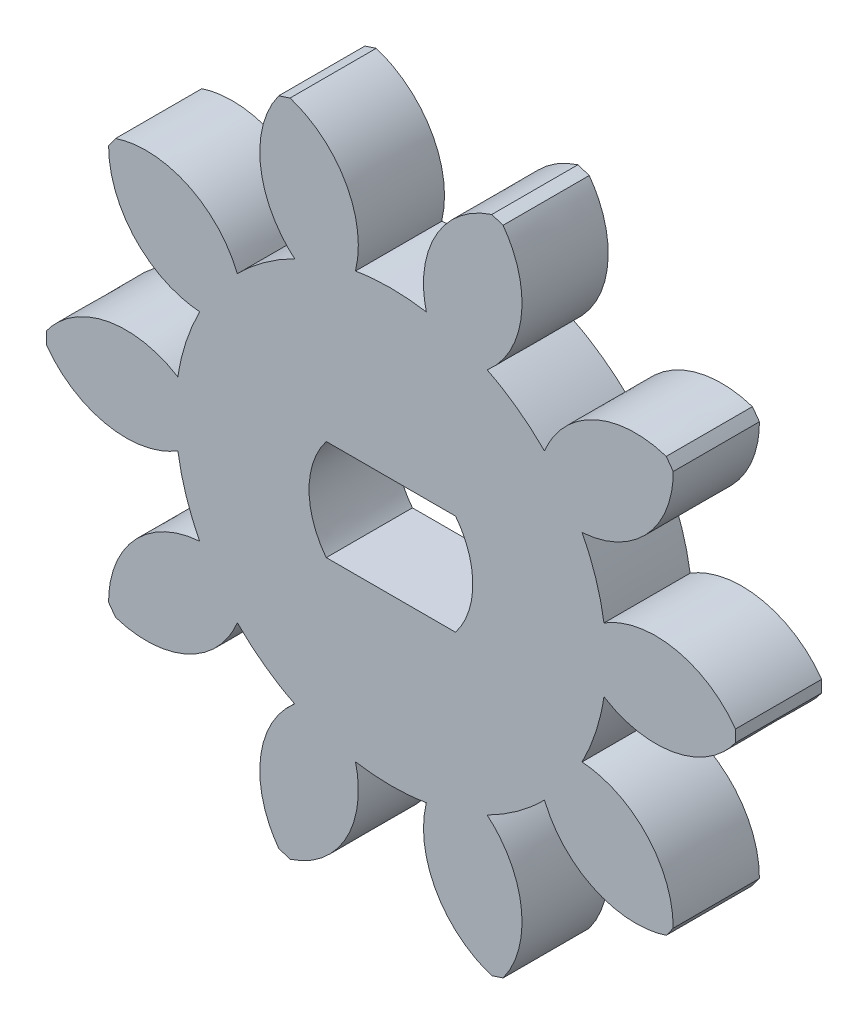
from build123d import *

# Parameters (mm, degrees)
SALIENTE_EXTRUIR1_DEPTH = 3


with BuildPart() as part:
    # Croquis1 → Saliente-Extruir1 (new body)
    with BuildSketch(Plane.XY):
        with BuildLine():
            add(Edge.make_bspline(
                [(389.936156465, -257.964269658), (389.256388965, -256.299793547), (387.405469799, -255.444131047), (385.697178688, -256.004589103)],
                knots=[0, 0, 0, 0, 1, 1, 1, 1], degree=3))
            add(Edge.make_bspline(
                [(385.697178688, -256.004589103), (385.614134799, -256.11479688), (385.533031188, -256.226451047), (385.453832577, -256.339481047)],
                knots=[0, 0, 0, 0, 1, 1, 1, 1], degree=3))
            add(Edge.make_bspline(
                [(385.453832577, -256.339481047), (385.448752577, -258.137377713), (386.834498966, -259.633261324), (388.627527299, -259.76541188)],
                knots=[0, 0, 0, 0, 1, 1, 1, 1], degree=3))
            add(Edge.make_bspline(
                [(388.627527299, -259.76541188), (388.245751188, -260.49993049), (387.988188132, -261.292586879), (387.86535091, -262.111207712)],
                knots=[0, 0, 0, 0, 1, 1, 1, 1], degree=3))
            add(Edge.make_bspline(
                [(387.86535091, -262.111207712), (386.337047021, -261.164211046), (384.336691189, -261.559886601), (383.284037578, -263.017423268)],
                knots=[0, 0, 0, 0, 1, 1, 1, 1], degree=3))
            add(Edge.make_bspline(
                [(383.284037578, -263.017423268), (383.281673967, -263.155394656), (383.281673967, -263.293401323), (383.284037578, -263.431372712)],
                knots=[0, 0, 0, 0, 1, 1, 1, 1], degree=3))
            add(Edge.make_bspline(
                [(383.284037578, -263.431372712), (384.336691189, -264.888909378), (386.337047021, -265.284584934), (387.86535091, -264.337588267)],
                knots=[0, 0, 0, 0, 1, 1, 1, 1], degree=3))
            add(Edge.make_bspline(
                [(387.86535091, -264.337588267), (387.988188132, -265.1562091), (388.245751188, -265.948865489), (388.627527299, -266.6833841)],
                knots=[0, 0, 0, 0, 1, 1, 1, 1], degree=3))
            add(Edge.make_bspline(
                [(388.627527299, -266.6833841), (386.834498966, -266.815534656), (385.448752577, -268.311418266), (385.453832577, -270.109314932)],
                knots=[0, 0, 0, 0, 1, 1, 1, 1], degree=3))
            add(Edge.make_bspline(
                [(385.453832577, -270.109314932), (385.533031188, -270.222344932), (385.614134799, -270.333999099), (385.697178688, -270.444206877)],
                knots=[0, 0, 0, 0, 1, 1, 1, 1], degree=3))
            add(Edge.make_bspline(
                [(385.697178688, -270.444206877), (387.405469799, -271.004664932), (389.256388965, -270.149002432), (389.936156465, -268.4845616)],
                knots=[0, 0, 0, 0, 1, 1, 1, 1], degree=3))
            add(Edge.make_bspline(
                [(389.936156465, -268.4845616), (390.516722854, -269.074617711), (391.191022298, -269.564484933), (391.931608687, -269.934337155)],
                knots=[0, 0, 0, 0, 1, 1, 1, 1], degree=3))
            add(Edge.make_bspline(
                [(391.931608687, -269.934337155), (390.558668132, -271.095152432), (390.316874243, -273.119885209), (391.377747576, -274.571424654)],
                knots=[0, 0, 0, 0, 1, 1, 1, 1], degree=3))
            add(Edge.make_bspline(
                [(391.377747576, -274.571424654), (391.508240076, -274.616333265), (391.639508687, -274.65894882), (391.771447576, -274.699341876)],
                knots=[0, 0, 0, 0, 1, 1, 1, 1], degree=3))
            add(Edge.make_bspline(
                [(391.771447576, -274.699341876), (393.482948964, -274.148620487), (394.477394242, -272.368433265), (394.049016186, -270.622324377)],
                knots=[0, 0, 0, 0, 1, 1, 1, 1], degree=3))
            add(Edge.make_bspline(
                [(394.049016186, -270.622324377), (394.86555563, -270.758426043), (395.69899313, -270.758426043), (396.515532574, -270.622324377)],
                knots=[0, 0, 0, 0, 1, 1, 1, 1], degree=3))
            add(Edge.make_bspline(
                [(396.515532574, -270.622324377), (396.087119241, -272.368433265), (397.081599797, -274.148620487), (398.793065907, -274.699341876)],
                knots=[0, 0, 0, 0, 1, 1, 1, 1], degree=3))
            add(Edge.make_bspline(
                [(398.793065907, -274.699341876), (398.925040074, -274.65894882), (399.056273407, -274.616333265), (399.186765907, -274.571424654)],
                knots=[0, 0, 0, 0, 1, 1, 1, 1], degree=3))
            add(Edge.make_bspline(
                [(399.186765907, -274.571424654), (400.247674518, -273.119885209), (400.005845351, -271.095152432), (398.632904796, -269.934337155)],
                knots=[0, 0, 0, 0, 1, 1, 1, 1], degree=3))
            add(Edge.make_bspline(
                [(398.632904796, -269.934337155), (399.373526463, -269.564484933), (400.047790629, -269.074617711), (400.628357018, -268.4845616)],
                knots=[0, 0, 0, 0, 1, 1, 1, 1], degree=3))
            add(Edge.make_bspline(
                [(400.628357018, -268.4845616), (401.308124518, -270.149002432), (403.159043684, -271.004664932), (404.867370072, -270.444206877)],
                knots=[0, 0, 0, 0, 1, 1, 1, 1], degree=3))
            add(Edge.make_bspline(
                [(404.867370072, -270.444206877), (404.950378683, -270.333999099), (405.031517572, -270.222344932), (405.110680906, -270.109314932)],
                knots=[0, 0, 0, 0, 1, 1, 1, 1], degree=3))
            add(Edge.make_bspline(
                [(405.110680906, -270.109314932), (405.115796183, -268.311418266), (403.730049795, -266.815534656), (401.936986184, -266.6833841)],
                knots=[0, 0, 0, 0, 1, 1, 1, 1], degree=3))
            add(Edge.make_bspline(
                [(401.936986184, -266.6833841), (402.318762295, -265.948865489), (402.576325351, -265.1562091), (402.699197851, -264.337588267)],
                knots=[0, 0, 0, 0, 1, 1, 1, 1], degree=3))
            add(Edge.make_bspline(
                [(402.699197851, -264.337588267), (404.227466461, -265.284584934), (406.227822294, -264.888909378), (407.280475905, -263.431372712)],
                knots=[0, 0, 0, 0, 1, 1, 1, 1], degree=3))
            add(Edge.make_bspline(
                [(407.280475905, -263.431372712), (407.282874794, -263.293401323), (407.282874794, -263.155394656), (407.280475905, -263.017423268)],
                knots=[0, 0, 0, 0, 1, 1, 1, 1], degree=3))
            add(Edge.make_bspline(
                [(407.280475905, -263.017423268), (406.227822294, -261.559886601), (404.227466461, -261.164211046), (402.699197851, -262.111207712)],
                knots=[0, 0, 0, 0, 1, 1, 1, 1], degree=3))
            add(Edge.make_bspline(
                [(402.699197851, -262.111207712), (402.576325351, -261.292586879), (402.318762295, -260.49993049), (401.936986184, -259.76541188)],
                knots=[0, 0, 0, 0, 1, 1, 1, 1], degree=3))
            add(Edge.make_bspline(
                [(401.936986184, -259.76541188), (403.730049795, -259.633261324), (405.115796183, -258.137377713), (405.110680906, -256.339481047)],
                knots=[0, 0, 0, 0, 1, 1, 1, 1], degree=3))
            add(Edge.make_bspline(
                [(405.110680906, -256.339481047), (405.031517572, -256.226451047), (404.950378683, -256.11479688), (404.867370072, -256.004589103)],
                knots=[0, 0, 0, 0, 1, 1, 1, 1], degree=3))
            add(Edge.make_bspline(
                [(404.867370072, -256.004589103), (403.159043684, -255.444131047), (401.308124518, -256.299793547), (400.628357018, -257.964269658)],
                knots=[0, 0, 0, 0, 1, 1, 1, 1], degree=3))
            add(Edge.make_bspline(
                [(400.628357018, -257.964269658), (400.047790629, -257.374178269), (399.373526463, -256.884311047), (398.632904796, -256.514458825)],
                knots=[0, 0, 0, 0, 1, 1, 1, 1], degree=3))
            add(Edge.make_bspline(
                [(398.632904796, -256.514458825), (400.005845351, -255.353643547), (400.247674518, -253.32891077), (399.186765907, -251.877371326)],
                knots=[0, 0, 0, 0, 1, 1, 1, 1], degree=3))
            add(Edge.make_bspline(
                [(399.186765907, -251.877371326), (399.056273407, -251.832462715), (398.925040074, -251.789847159), (398.793065907, -251.749454104)],
                knots=[0, 0, 0, 0, 1, 1, 1, 1], degree=3))
            add(Edge.make_bspline(
                [(398.793065907, -251.749454104), (397.081599797, -252.300175492), (396.087119241, -254.080362714), (396.515532574, -255.826471603)],
                knots=[0, 0, 0, 0, 1, 1, 1, 1], degree=3))
            add(Edge.make_bspline(
                [(396.515532574, -255.826471603), (395.69899313, -255.690369936), (394.86555563, -255.690369936), (394.049016186, -255.826471603)],
                knots=[0, 0, 0, 0, 1, 1, 1, 1], degree=3))
            add(Edge.make_bspline(
                [(394.049016186, -255.826471603), (394.477394242, -254.080362714), (393.482948964, -252.300175492), (391.771447576, -251.749454104)],
                knots=[0, 0, 0, 0, 1, 1, 1, 1], degree=3))
            add(Edge.make_bspline(
                [(391.771447576, -251.749454104), (391.639508687, -251.789847159), (391.508240076, -251.832462715), (391.377747576, -251.877371326)],
                knots=[0, 0, 0, 0, 1, 1, 1, 1], degree=3))
            add(Edge.make_bspline(
                [(391.377747576, -251.877371326), (390.316874243, -253.32891077), (390.558668132, -255.353643547), (391.931608687, -256.514458825)],
                knots=[0, 0, 0, 0, 1, 1, 1, 1], degree=3))
            add(Edge.make_bspline(
                [(391.931608687, -256.514458825), (391.191022298, -256.884311047), (390.516722854, -257.374178269), (389.936156465, -257.964269658)],
                knots=[0, 0, 0, 0, 1, 1, 1, 1], degree=3))
        make_face()
        with BuildLine():
            Line((393.032275353, -264.974387434), (397.532273408, -264.974387434))
            add(Edge.make_bspline(
                [(397.532273408, -264.974387434), (398.332832018, -263.945087712), (398.332832018, -262.503708268), (397.532273408, -261.474408546)],
                knots=[0, 0, 0, 0, 1, 1, 1, 1], degree=3))
            Line((397.532273408, -261.474408546), (393.032275353, -261.474408546))
            add(Edge.make_bspline(
                [(393.032275353, -261.474408546), (392.231681464, -262.503708268), (392.231681464, -263.945087712), (393.032275353, -264.974387434)],
                knots=[0, 0, 0, 0, 1, 1, 1, 1], degree=3))
        make_face(mode=Mode.SUBTRACT)
    extrude(amount=SALIENTE_EXTRUIR1_DEPTH)


solid = part.part
